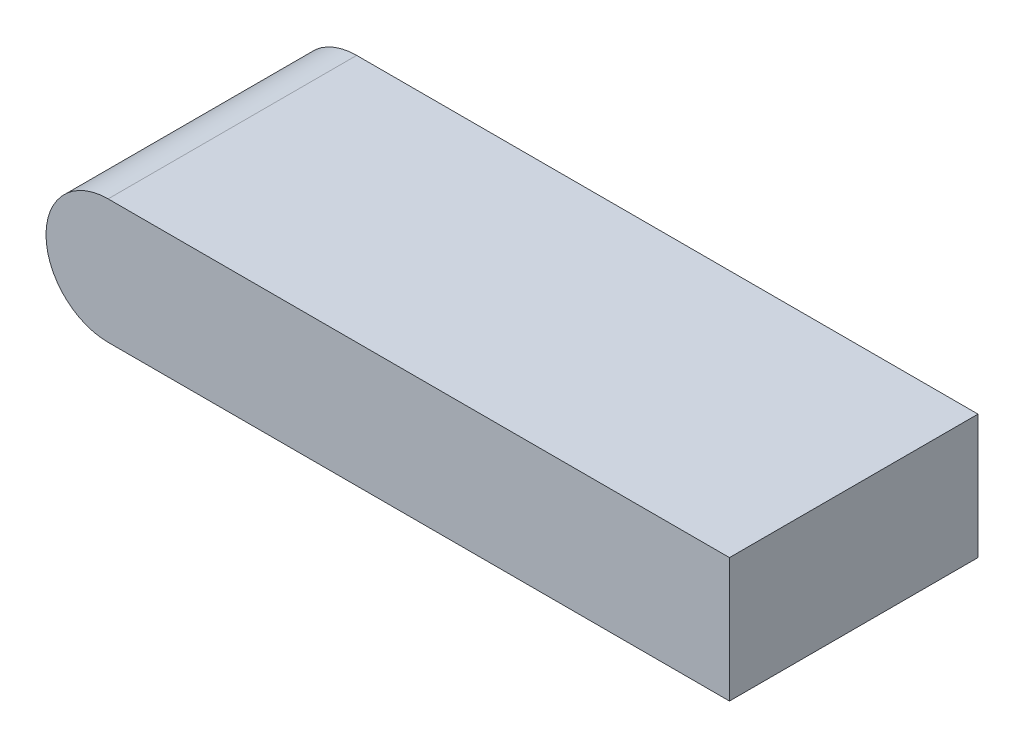
from build123d import *

# Parameters (mm, degrees)
SKETCH_1_W      = 20
SKETCH_1_H      = 8
EXTRUDE_1_DEPTH = 4
SKETCH_2_R      = 2
EXTRUDE_2_DEPTH = 8


with BuildPart() as part:
    # 草图1 → 凸台-拉伸1 (new body)
    with BuildSketch(Plane(origin=(0, 0, 0), x_dir=(1, 0, 0), z_dir=(0, 1, 0))):
        Rectangle(SKETCH_1_W, SKETCH_1_H)
    extrude(amount=EXTRUDE_1_DEPTH)

    # 草图2 → 凸台-拉伸2 (add)
    with BuildSketch(Plane.XY.offset(4)):
        with Locations((-10, 2)):
            Circle(SKETCH_2_R)
    extrude(amount=-EXTRUDE_2_DEPTH)


solid = part.part
